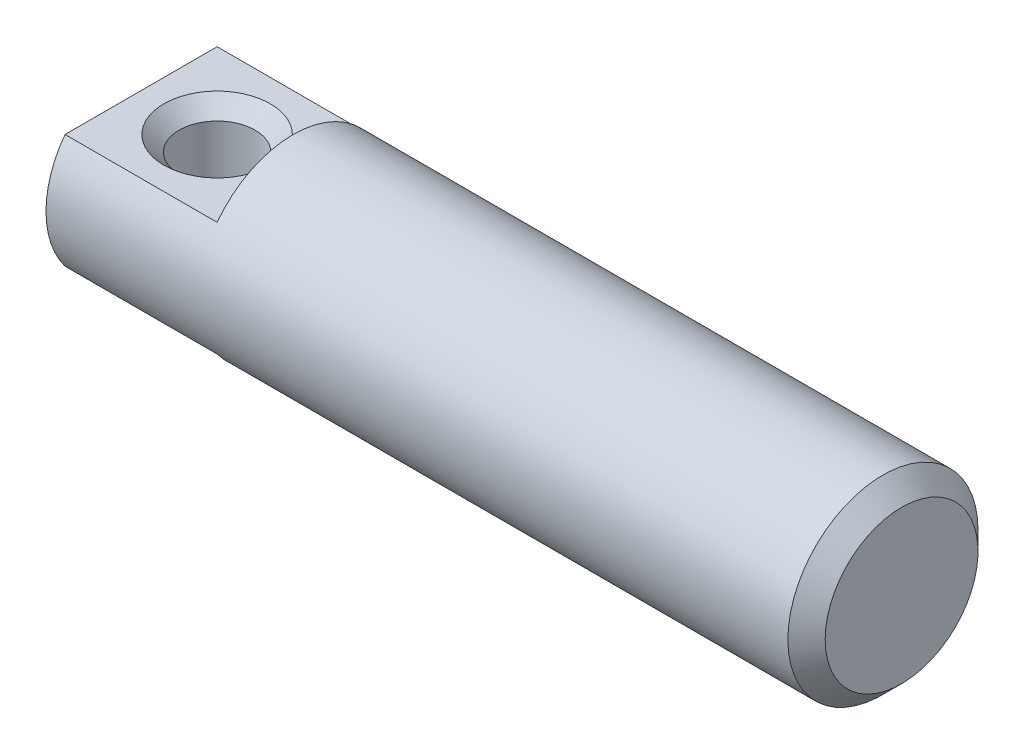
from build123d import *

# Parameters (mm, degrees)
CUT_EXTRUDE1_DEPTH      = 2.5
CUT_EXTRUDE1_DEPTH_BACK = 2.5


with BuildPart() as part:
    # Sketch1 → Revolve1 (revolve)
    with BuildSketch(Plane.XY):
        Polygon((0, 0), (0, 2.5), (19.5095, 2.5), (20, 2.0095), (20, 0), align=None)
    revolve(axis=Axis((20, 0, 0), (-1, 0, 0)))

    # Sketch2 → Cut-Extrude1 (cut, two sides: drawn at the far end of the back side and taken through both)
    with BuildSketch(Plane.XY.offset(-CUT_EXTRUDE1_DEPTH_BACK)):
        Polygon((-1, 3), (-1, -3), (4, -3), (4, -1.5), (0, -1.5), (0, 1.5), (4, 1.5), (4, 3), align=None)
    extrude(amount=CUT_EXTRUDE1_DEPTH + CUT_EXTRUDE1_DEPTH_BACK, mode=Mode.SUBTRACT)

    # Sketch3 → Cut-Revolve1 (revolve, cut)
    with BuildSketch(Plane.XY):
        Polygon((2, 1.5), (3.4, 1.5), (3, 1.1), (3, -1.1), (3.4, -1.5), (2, -1.5), align=None)
    revolve(axis=Axis((2, -1.5, 0), (0, 1, 0)), mode=Mode.SUBTRACT)


solid = part.part
